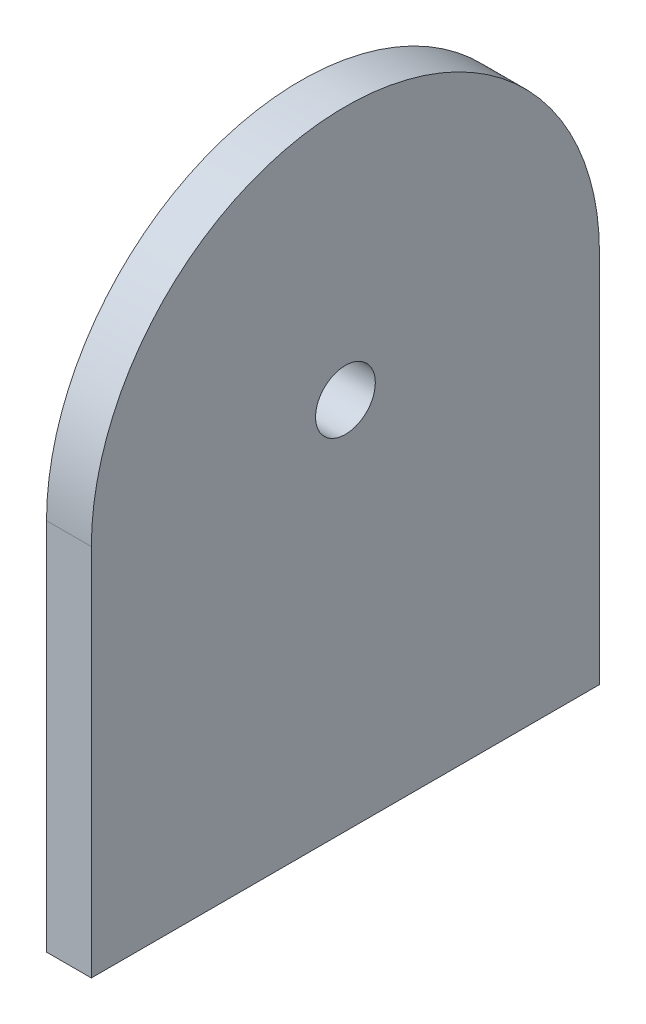
from build123d import *

# Parameters (mm, degrees)
CROQUIS1_R              = 2
SALIENTE_EXTRUIR1_DEPTH = 3


with BuildPart() as part:
    # Croquis1 → Saliente-Extruir1 (new body)
    with BuildSketch(Plane(origin=(0, 0, 0), x_dir=(0, 0, -1), z_dir=(1, 0, 0))):
        with BuildLine():
            Line((0, 0), (34, 0))
            Line((34, 0), (34, 25))
            ThreePointArc((34, 25), (17, 42), (0, 25))
            Line((0, 25), (0, 0))
        make_face()
        with Locations((17, 25)):
            Circle(CROQUIS1_R, mode=Mode.SUBTRACT)
    extrude(amount=SALIENTE_EXTRUIR1_DEPTH)


solid = part.part
